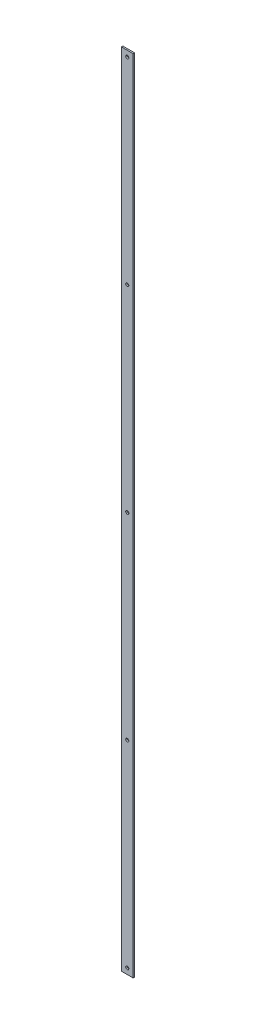
from build123d import *

# Parameters (mm, degrees)
SKETCH1_W           = 25.4
SKETCH1_H           = 1727.2
BOSS_EXTRUDE1_DEPTH = 3.175
SKETCH2_R           = 3.3655
CUT_EXTRUDE1_DEPTH  = 4.175
LPATTERN1_COUNT     = 5
LPATTERN1_PITCH     = 425.45


with BuildPart() as part:
    # Sketch1 → Boss-Extrude1 (new body)
    with BuildSketch(Plane.XY):
        with Locations((12.7, 863.6)):
            Rectangle(SKETCH1_W, SKETCH1_H)
    extrude(amount=BOSS_EXTRUDE1_DEPTH)

    # Sketch2 → Cut-Extrude1 (cut, through all)
    with BuildSketch(Plane.XY.offset(3.175)):
        with Locations((12.7, 12.7)):
            Circle(SKETCH2_R)
    cut_extrude1 = extrude(amount=-CUT_EXTRUDE1_DEPTH, mode=Mode.SUBTRACT)

    # LPattern1: Cut-Extrude1 ×5
    with Locations(*[(0, i * LPATTERN1_PITCH, 0) for i in range(1, LPATTERN1_COUNT)]):
        add(cut_extrude1, mode=Mode.SUBTRACT)


solid = part.part
